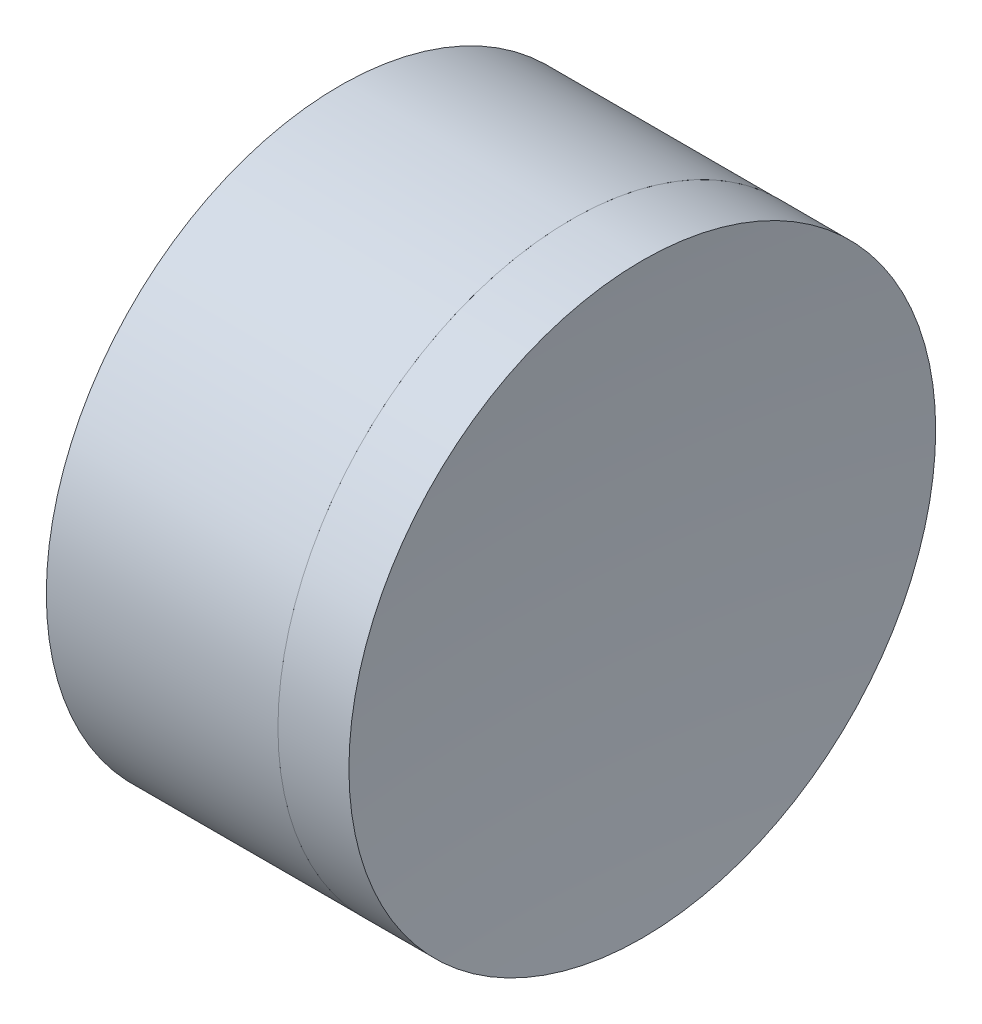
from build123d import *


with BuildPart() as part:
    # 草图1 one side → 旋转1 (revolve)
    with BuildSketch(Plane(origin=(0, 0, 0), x_dir=(1, 0, 0), z_dir=(0, 1, 0)), mode=Mode.PRIVATE) as revolve_1_sk:
        with BuildLine():
            Line((228.877381727, 6.25), (223.943161324, 6.25))
            ThreePointArc((223.943161324, 6.25), (224.551549528, 3.151283901), (224.755479542, 0))
            Line((224.755479542, 0), (227.755479542, 0))
            ThreePointArc((227.755479542, 0), (228.038178762, 3.174947421), (228.877381727, 6.25))
        make_face()
    revolve(revolve_1_sk.sketch.rotate(Axis((-0.816062176, 0, 0), (1, 0, 0)), 180), axis=Axis((-0.816062176, 0, 0), (1, 0, 0)))  # turned: the seam where the file's is


with BuildPart() as body_2:
    # 草图2 one side → 旋转3 (revolve)
    with BuildSketch(Plane(origin=(0, 0, 0), x_dir=(1, 0, 0), z_dir=(0, 1, 0)), mode=Mode.PRIVATE) as revolve_3_sk:
        with BuildLine():
            Line((230.389390078, 6.25), (228.877381727, 6.25))
            ThreePointArc((228.877381727, 6.25), (228.038178762, 3.174947421), (227.755479542, 0))
            Line((227.755479542, 0), (230.095479542, 0))
            ThreePointArc((230.095479542, 0), (230.168997754, 3.128453428), (230.389390078, 6.25))
        make_face()
    revolve(revolve_3_sk.sketch.rotate(Axis((223.943161324, 0, 0), (1, 0, 0)), 180), axis=Axis((223.943161324, 0, 0), (1, 0, 0)))  # turned: the seam where the file's is


solid = Compound([part.part, body_2.part])
